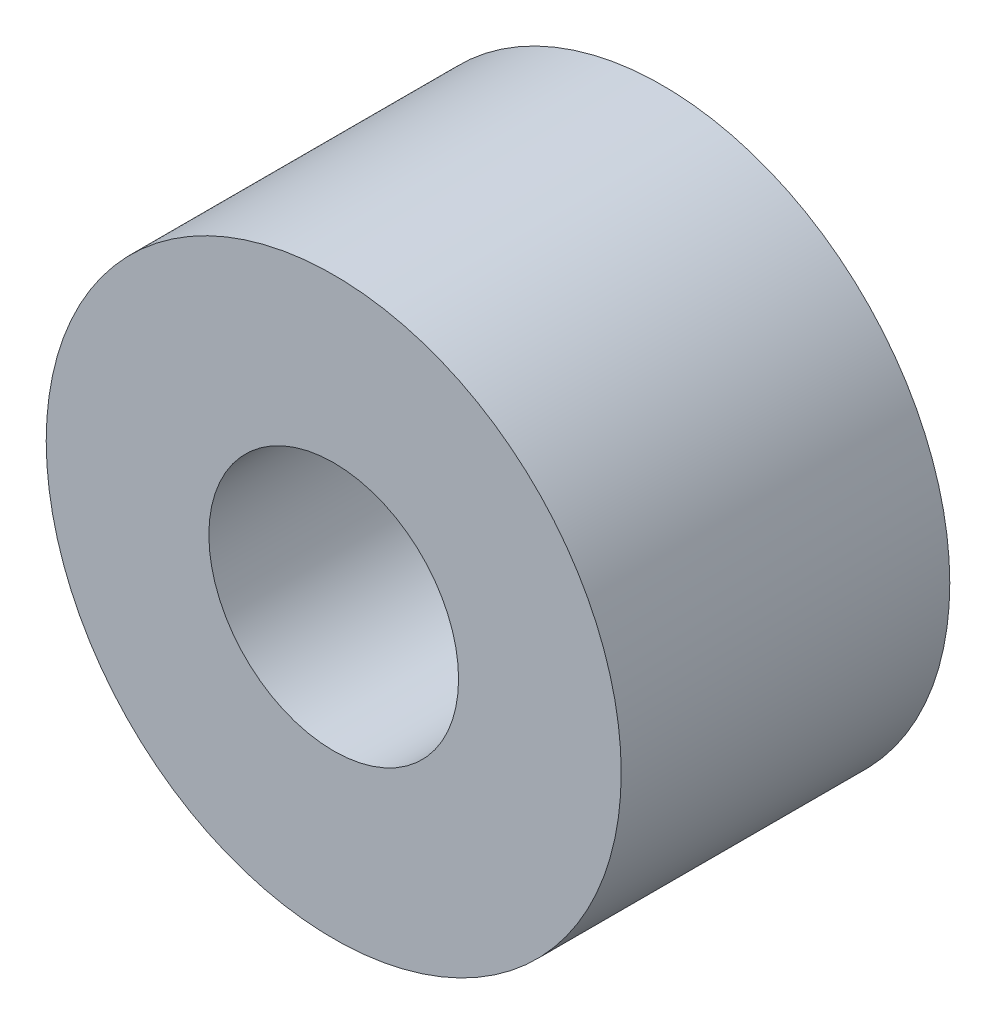
from build123d import *

# Parameters (mm, degrees)
SKETCH1_R      = 5.55625
EXTRUDE1_DEPTH = 3.175
SKETCH2_R      = 2.413
EXTRUDE2_DEPTH = 7.35


with BuildPart() as part:
    # Sketch1 → Extrude1 (new body, symmetric)
    with BuildSketch(Plane.XY):
        Circle(SKETCH1_R)
    extrude(amount=EXTRUDE1_DEPTH, both=True)

    # Sketch2 → Extrude2 (cut, through all)
    with BuildSketch(Plane.XY.offset(3.175)):
        Circle(SKETCH2_R)
    extrude(amount=-EXTRUDE2_DEPTH, mode=Mode.SUBTRACT)


solid = part.part
